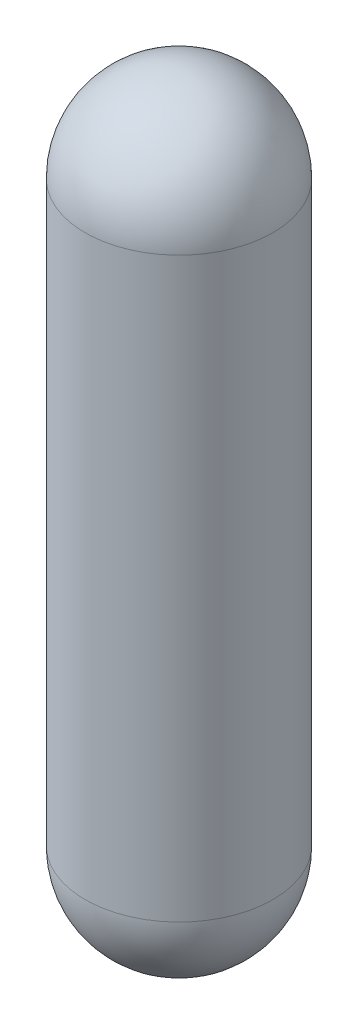
from build123d import *


with BuildPart() as part:
    # Sketch1 → Revolve1 (revolve)
    with BuildSketch(Plane.XY):
        with BuildLine():
            Line((0, 1766.670539033), (0, 2306.420539033))
            ThreePointArc((0, 2306.420539033), (381.660885145, 2148.331424179), (539.75, 1766.670539033))
            Line((539.75, 1766.670539033), (539.75, -1553.829460967))
            ThreePointArc((539.75, -1553.829460967), (381.660885145, -1935.490346112), (0, -2093.579460967))
            Line((0, -2093.579460967), (0, -1553.829460967))
            Line((0, -1553.829460967), (0, 1766.670539033))
        make_face()
    revolve(axis=Axis((0, -1553.829460967, 0), (0, 1, 0)))


solid = part.part
